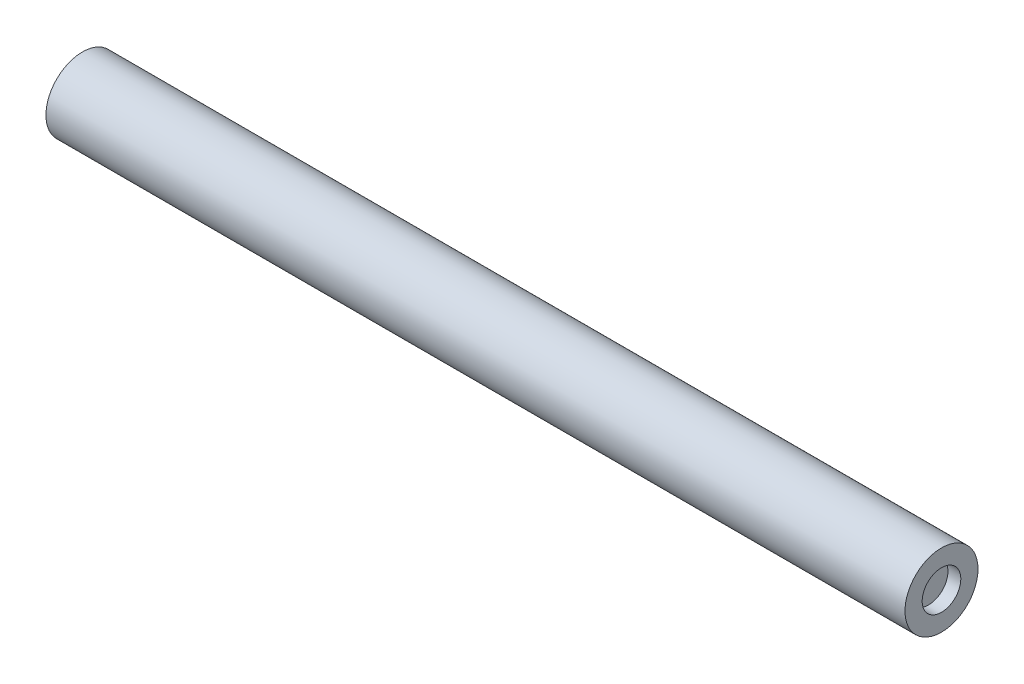
from build123d import *

# Parameters (mm, degrees)
SKETCH1_R           = 8.636
BOSS_EXTRUDE1_DEPTH = 203.2
SKETCH2_R           = 4.572
CUT_EXTRUDE1_DEPTH  = 3.048
SKETCH3_R           = 2.794
CUT_EXTRUDE2_DEPTH  = 14.478


with BuildPart() as part:
    # Sketch1 → Boss-Extrude1 (new body)
    with BuildSketch(Plane(origin=(0, 0, 0), x_dir=(0, 0, -1), z_dir=(1, 0, 0))):
        Circle(SKETCH1_R)
    extrude(amount=BOSS_EXTRUDE1_DEPTH)

    # Sketch2 → Cut-Extrude1 (cut)
    with BuildSketch(Plane(origin=(203.2, 0, 0), x_dir=(0, 0, -1), z_dir=(1, 0, 0))):
        Circle(SKETCH2_R)
    extrude(amount=-CUT_EXTRUDE1_DEPTH, mode=Mode.SUBTRACT)

    # Sketch3 → Cut-Extrude2 (cut)
    with BuildSketch(Plane.ZY):
        Circle(SKETCH3_R)
    extrude(amount=-CUT_EXTRUDE2_DEPTH, mode=Mode.SUBTRACT)


solid = part.part
